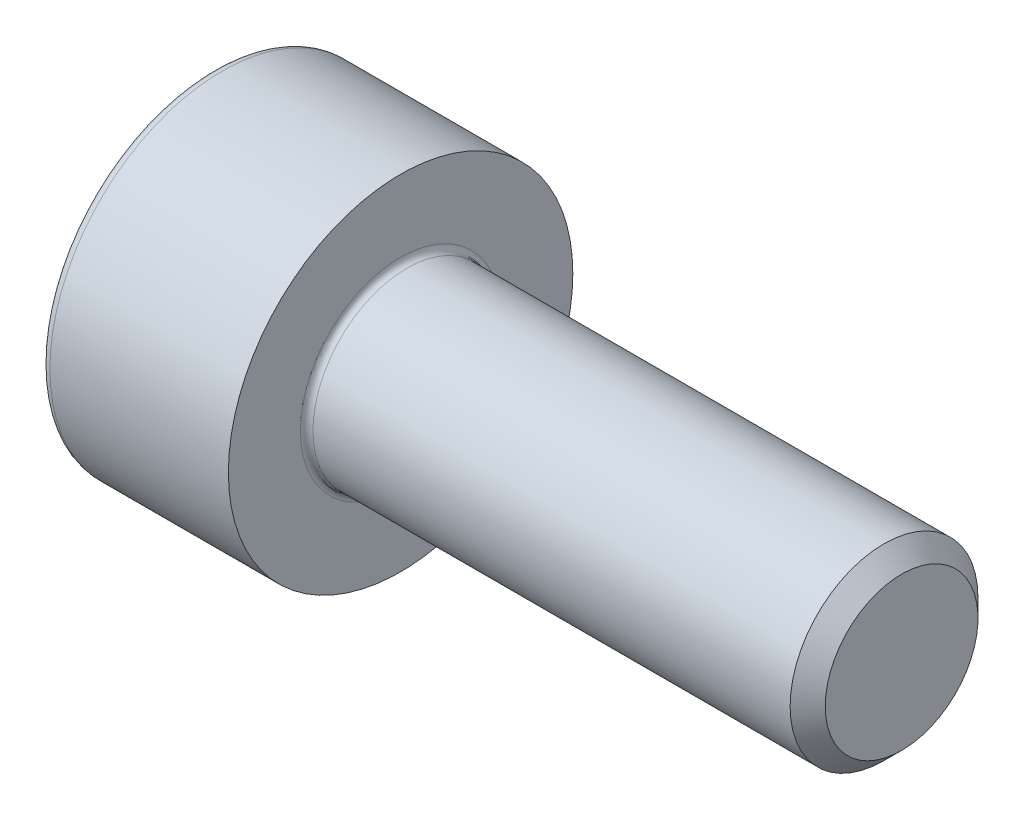
from build123d import *

# Parameters (mm, degrees)
FILLET1_R   = 0.1
FILLET2_R   = 0.15
HEX_2_DEPTH = 1.3


with BuildPart() as part:
    # BodySke → Base-Revolve (revolve)
    with BuildSketch(Plane.XY):
        Polygon((0, 0), (0, 2.75), (3, 2.75), (3, 1.5), (10.7195, 1.5), (11, 1.2195), (11, 0), align=None)
    revolve(axis=Axis((-31.75, 0, 0), (1, 0, 0)))

    # Fillet1
    fillet1_edges = [part.edges().sort_by_distance(p)[0] for p in [
        (3, -1.5, 0),
    ]]
    fillet(fillet1_edges, radius=FILLET1_R)

    # Fillet2
    fillet2_edges = [part.edges().sort_by_distance(p)[0] for p in [
        (0, -2.75, 0),
    ]]
    fillet(fillet2_edges, radius=FILLET2_R)

    # Sketch2 → Hex-PreBroach (revolve, cut)
    with BuildSketch(Plane.XY):
        Polygon((0, 1.28), (1.3, 1.28), (2.039008345, 0), (0, 0), align=None)
    revolve(axis=Axis((0, 0, 0), (1, 0, 0)), mode=Mode.SUBTRACT)

    # Sketch3 → Hex 2 (cut)
    with BuildSketch(Plane(origin=(0, 0, 0), x_dir=(0, 0.5, 0.866025404), z_dir=(-1, 0, 0))):
        Polygon((0.739008345, 1.28), (-0.739008345, 1.28), (-1.478016689, 0), (-0.739008345, -1.28), (0.739008345, -1.28), (1.478016689, 0), align=None)
    extrude(amount=-HEX_2_DEPTH, mode=Mode.SUBTRACT)


solid = part.part
